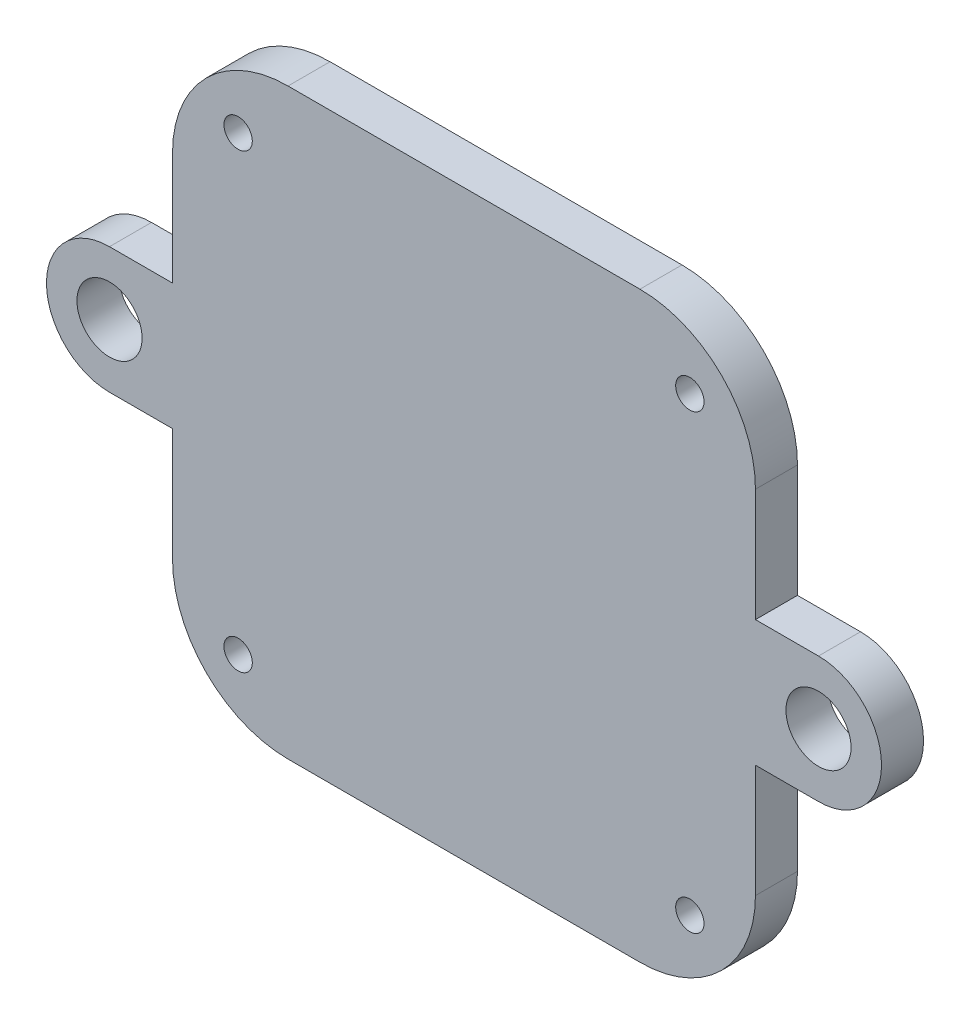
from build123d import *

# Parameters (mm, degrees)
SKETCH1_R                                      = 1.35
SKETCH1_R_2                                    = 6
SKETCH1_R_3                                    = 3.1
BOSS_EXTRUDE1_DEPTH                            = 4
CSK_FOR_M2_5_FLAT_HEAD_MACHINE_SCREW1_AT_COUNT = 2
CSK_FOR_M2_5_FLAT_HEAD_MACHINE_SCREW1_AT_PITCH = 43
CSK_FOR_M2_5_FLAT_HEAD_MACHINE_SCREW_2_COUNT   = 2
CSK_FOR_M2_5_FLAT_HEAD_MACHINE_SCREW_2_PITCH   = 60.811183182
CSK_FOR_M2_5_FLAT_HEAD_MACHINE_SCREW_3_COUNT   = 2
CSK_FOR_M2_5_FLAT_HEAD_MACHINE_SCREW_3_PITCH   = 43


with BuildPart() as part:
    # Sketch1 → Boss-Extrude1 (new body)
    with BuildSketch(Plane.XY):
        with BuildLine():
            Line((-27.744938631, 6), (27.744938631, 6))
            Line((27.744938631, 6), (27.744938631, 16.75))
            ThreePointArc((27.744938631, 16.75), (24.524595568, 24.52459576), (16.749999729, 27.744938631))
            Line((16.749999729, 27.744938631), (-16.75, 27.744938631))
            ThreePointArc((-16.75, 27.744938631), (-24.524595664, 24.524595664), (-27.744938631, 16.75))
            Line((-27.744938631, 16.75), (-27.744938631, 6))
        make_face()
        with Locations((-21.5, 21.5)):
            Circle(SKETCH1_R, mode=Mode.SUBTRACT)
        with Locations((21.5, 21.5)):
            Circle(SKETCH1_R, mode=Mode.SUBTRACT)
        Polygon((-27.744938631, -6), (27.744938631, -6), (27.744938631, 0), (27.744938631, 6), (-27.744938631, 6), (-27.744938631, 0), align=None)
        with BuildLine():
            Line((-16.749999529, -27.744938631), (16.75, -27.744938631))
            ThreePointArc((16.75, -27.744938631), (24.524595836, -24.524595492), (27.744938631, -16.749999513))
            Line((27.744938631, -16.749999513), (27.744938631, -6))
            Line((27.744938631, -6), (-27.744938631, -6))
            Line((-27.744938631, -6), (-27.744938631, -16.75))
            ThreePointArc((-27.744938631, -16.75), (-24.524595498, -24.524595831), (-16.749999529, -27.744938631))
        make_face()
        with Locations((-21.5, -21.5)):
            Circle(SKETCH1_R, mode=Mode.SUBTRACT)
        with Locations((21.5, -21.5)):
            Circle(SKETCH1_R, mode=Mode.SUBTRACT)
        with BuildLine():
            Line((-33.744938608, -6), (-27.744938631, -6))
            Line((-27.744938631, -6), (-27.744938631, 0))
            ThreePointArc((-27.744938631, 0), (-29.502297935, -4.242640679), (-33.744938608, -6))
        make_face()
        with BuildLine():
            ThreePointArc((-33.744938605, 6), (-29.502297934, 4.242640678), (-27.744938631, 0))
            Line((-27.744938631, 0), (-27.744938631, 6))
            Line((-27.744938631, 6), (-33.744938605, 6))
        make_face()
        with Locations((-33.744938631, 0)):
            Circle(SKETCH1_R_2)
        with Locations((-33.744938631, 0)):
            Circle(SKETCH1_R_3, mode=Mode.SUBTRACT)
        with BuildLine():
            Line((27.744938631, 6), (27.744938631, 0))
            ThreePointArc((27.744938631, 0), (29.502297943, 4.242640687), (33.744938631, 6))
            Line((33.744938631, 6), (27.744938631, 6))
        make_face()
        with BuildLine():
            Line((27.744938631, 0), (27.744938631, -6))
            Line((27.744938631, -6), (33.744938631, -6))
            ThreePointArc((33.744938631, -6), (29.502297943, -4.242640687), (27.744938631, 0))
        make_face()
        with Locations((33.744938631, 0)):
            Circle(SKETCH1_R_2)
        with Locations((33.744938631, 0)):
            Circle(SKETCH1_R_3, mode=Mode.SUBTRACT)
    extrude(amount=-BOSS_EXTRUDE1_DEPTH)

    # Sketch3 → CSK for M2.5 Flat Head Machine Screw1 (revolve, cut)
    with BuildSketch(Plane(origin=(21.5, 21.5, -4), x_dir=(0, 1, 0), z_dir=(1, 0, 0))):
        Polygon((0, 0), (0, 4), (1.25, 4), (1.25, 1.55), (2.5, 0.3), (2.5, 0), align=None)
    csk_for_m2_5_flat_head_machine_screw1 = revolve(axis=Axis((21.5, 21.5, -10.35), (0, 0, 1)), mode=Mode.SUBTRACT)

    # CSK for M2.5 Flat Head Machine Screw1 at: CSK for M2.5 Flat Head Machine Screw1 ×2
    with Locations(*[(-i * CSK_FOR_M2_5_FLAT_HEAD_MACHINE_SCREW1_AT_PITCH, 0, 0) for i in range(1, CSK_FOR_M2_5_FLAT_HEAD_MACHINE_SCREW1_AT_COUNT)]):
        add(csk_for_m2_5_flat_head_machine_screw1, mode=Mode.SUBTRACT)

    # CSK for M2.5 Flat Head Machine Screw 2: CSK for M2.5 Flat Head Machine Screw1 ×2
    with Locations(*[Vector(-0.707106781, -0.707106781, 0) * (i * CSK_FOR_M2_5_FLAT_HEAD_MACHINE_SCREW_2_PITCH) for i in range(1, CSK_FOR_M2_5_FLAT_HEAD_MACHINE_SCREW_2_COUNT)]):
        add(csk_for_m2_5_flat_head_machine_screw1, mode=Mode.SUBTRACT)

    # CSK for M2.5 Flat Head Machine Screw 3: CSK for M2.5 Flat Head Machine Screw1 ×2
    with Locations(*[(0, -i * CSK_FOR_M2_5_FLAT_HEAD_MACHINE_SCREW_3_PITCH, 0) for i in range(1, CSK_FOR_M2_5_FLAT_HEAD_MACHINE_SCREW_3_COUNT)]):
        add(csk_for_m2_5_flat_head_machine_screw1, mode=Mode.SUBTRACT)


solid = part.part
